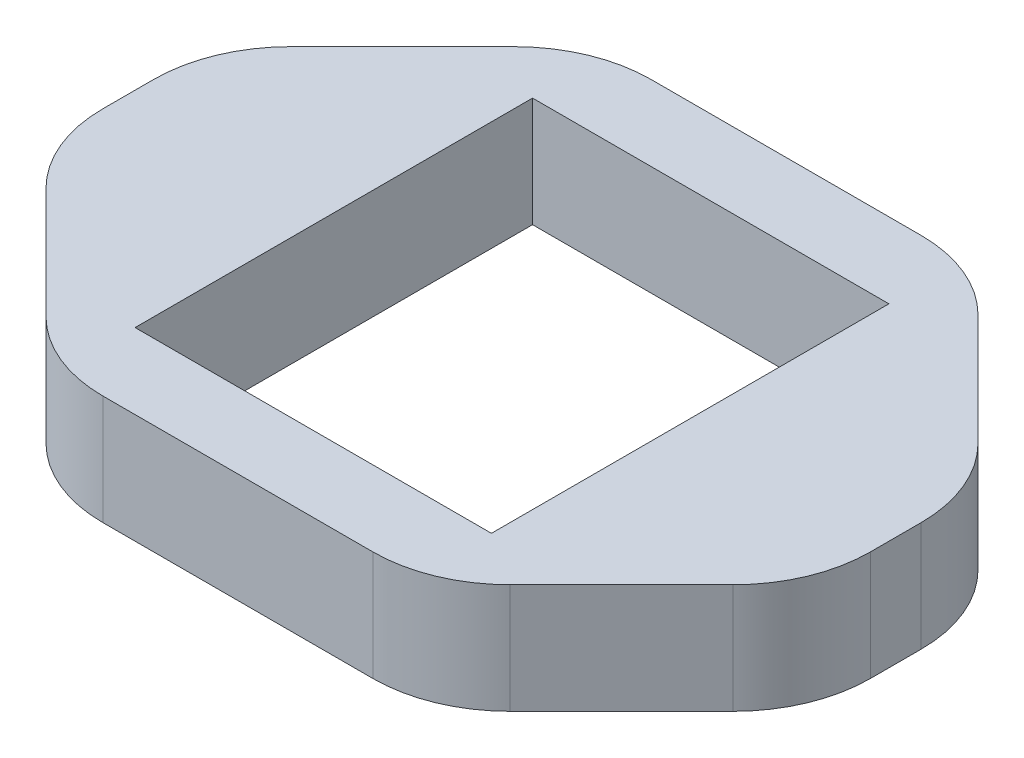
from build123d import *

# Parameters (mm, degrees)
ESQUISSE1_W             = 28
ESQUISSE1_H             = 20
BOSS_EXTRU_1_DEPTH      = 4
ESQUISSE2_W             = 13
ESQUISSE2_H             = 14.5
ENL_V_MAT_EXTRU_1_DEPTH = 4
ENL_V_MAT_EXTRU_2_DEPTH = 4
CONG_2_R                = 5


with BuildPart() as part:
    # Esquisse1 → Boss.-Extru.1 (new body)
    with BuildSketch(Plane(origin=(0, 0, 0), x_dir=(1, 0, 0), z_dir=(0, 1, 0))):
        Rectangle(ESQUISSE1_W, ESQUISSE1_H)
    extrude(amount=BOSS_EXTRU_1_DEPTH)

    # Esquisse2 → Enlèv. mat.-Extru.1 (cut)
    with BuildSketch(Plane(origin=(0, 4, 0), x_dir=(1, 0, 0), z_dir=(0, 1, 0))):
        Rectangle(ESQUISSE2_W, ESQUISSE2_H)
    extrude(amount=-ENL_V_MAT_EXTRU_1_DEPTH, mode=Mode.SUBTRACT)

    # Esquisse3 → Enlèv. mat.-Extru.2 (cut)
    with BuildSketch(Plane(origin=(0, 4, 0), x_dir=(1, 0, 0), z_dir=(0, 1, 0))):
        Polygon((-14, 10), (-14, 3), (-7, 10), align=None)
        Polygon((14, 10), (7, 10), (14, 3), align=None)
        Polygon((14, -3), (7, -10), (14, -10), align=None)
        Polygon((-7, -10), (-14, -3), (-14, -10), align=None)
    extrude(amount=-ENL_V_MAT_EXTRU_2_DEPTH, mode=Mode.SUBTRACT)

    # Congé2
    cong_2_edges = [part.edges().sort_by_distance(p)[0] for p in [
        (-14, 2, 3),
        (-7, 2, 10),
        (7, 2, 10),
        (14, 2, 3),
        (14, 2, -3),
        (7, 2, -10),
        (-14, 2, -3),
        (-7, 2, -10),
    ]]
    fillet(cong_2_edges, radius=CONG_2_R)


solid = part.part
